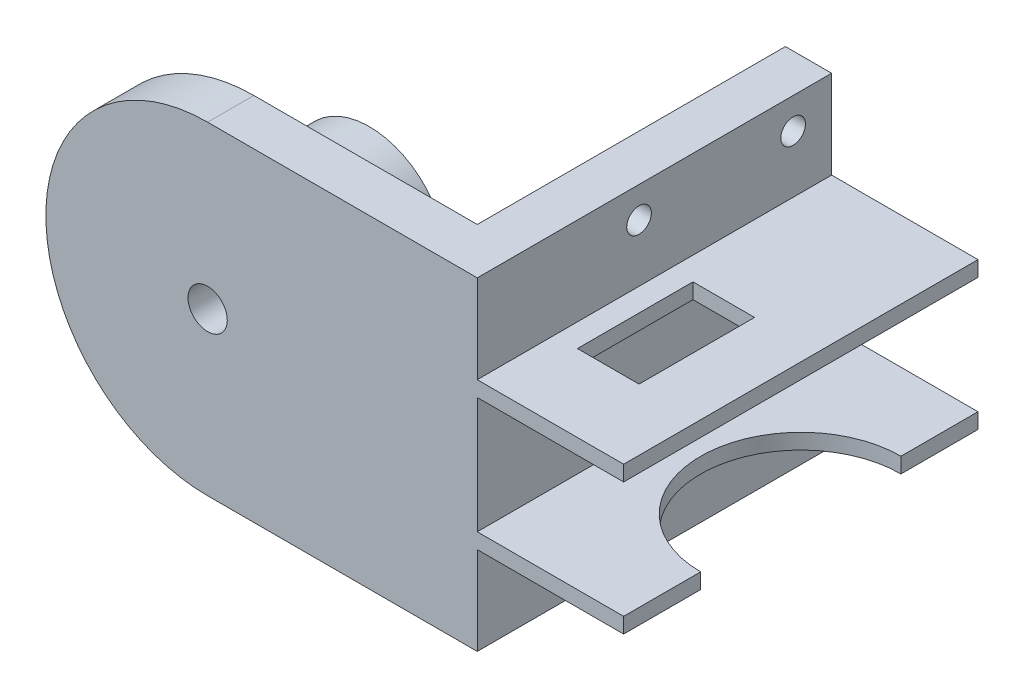
from build123d import *

# Parameters (mm, degrees)
SKETCH_1_R          = 10
SKETCH_1_R_2        = 2.55
EXTRUDE_1_DEPTH     = 15
SKETCH_3_R          = 1.6
CUT_EXTRUDE_1_DEPTH = 21
EXTRUDE_2_DEPTH     = 6
SKETCH_6_R          = 2.55
CUT_EXTRUDE_2_DEPTH = 10
SKETCH_7_W          = 40
SKETCH_7_H          = 42
EXTRUDE_3_DEPTH     = 6
SKETCH_8_R          = 1.6
CUT_EXTRUDE_3_DEPTH = 6
SKETCH_9_W          = 46
SKETCH_9_H          = 2
EXTRUDE_4_DEPTH     = 19
SKETCH_10_R         = 13
CUT_EXTRUDE_4_DEPTH = 8
SKETCH_11_W         = 8
SKETCH_11_H         = 15
CUT_EXTRUDE_5_DEPTH = 8


with BuildPart() as part:
    # 草图1 → 凸台-拉伸1 (new body)
    with BuildSketch(Plane.XY):
        with Locations((-2.14168272, 2.06384273)):
            Circle(SKETCH_1_R)
        with Locations((-2.14168272, 2.06384273)):
            Circle(SKETCH_1_R_2, mode=Mode.SUBTRACT)
    extrude(amount=EXTRUDE_1_DEPTH)

    # 草图3 → 切除-拉伸1 (cut, through all)
    with BuildSketch(Plane(origin=(7.85831728, 0, 0), x_dir=(0, 0, -1), z_dir=(1, 0, 0))):
        with Locations((-7.5, 2.06384273)):
            Circle(SKETCH_3_R)
    extrude(amount=-CUT_EXTRUDE_1_DEPTH, mode=Mode.SUBTRACT)

    # 草图5 → 凸台-拉伸2 (add)
    with BuildSketch(Plane.XY.offset(15)):
        with BuildLine():
            Line((-2.14168272, 23.06384273), (32.85831728, 23.06384273))
            Line((32.85831728, 23.06384273), (32.85831728, -18.93615727))
            Line((32.85831728, -18.93615727), (-2.14168272, -18.93615727))
            ThreePointArc((-2.14168272, -18.93615727), (-23.14168272, 2.06384273), (-2.14168272, 23.06384273))
        make_face()
    extrude(amount=EXTRUDE_2_DEPTH)

    # 草图6 → 切除-拉伸2 (cut)
    with BuildSketch(Plane(origin=(0, 0, 15), x_dir=(-1, 0, 0), z_dir=(0, 0, -1))):
        with Locations((2.14168272, 2.06384273)):
            Circle(SKETCH_6_R)
    extrude(amount=-CUT_EXTRUDE_2_DEPTH, mode=Mode.SUBTRACT)

    # 草图7 → 凸台-拉伸3 (add)
    with BuildSketch(Plane(origin=(32.85831728, 0, 0), x_dir=(0, 0, -1), z_dir=(1, 0, 0))):
        with Locations((5, 2.06384273)):
            Rectangle(SKETCH_7_W, SKETCH_7_H)
    extrude(amount=-EXTRUDE_3_DEPTH)

    # 草图8 → 切除-拉伸3 (cut)
    with BuildSketch(Plane(origin=(32.85831728, 0, 0), x_dir=(0, 0, -1), z_dir=(1, 0, 0))):
        with Locations((0, 19.06384273)):
            Circle(SKETCH_8_R)
        with Locations((0, -14.93615727)):
            Circle(SKETCH_8_R)
        with Locations((20, -14.93615727)):
            Circle(SKETCH_8_R)
        with Locations((20, 19.06384273)):
            Circle(SKETCH_8_R)
    extrude(amount=-CUT_EXTRUDE_3_DEPTH, mode=Mode.SUBTRACT)

    # 草图9 → 凸台-拉伸4 (add)
    with BuildSketch(Plane(origin=(32.85831728, 0, 0), x_dir=(0, 0, -1), z_dir=(1, 0, 0))):
        with Locations((2, 10.61384273)):
            Rectangle(SKETCH_9_W, SKETCH_9_H)
        with Locations((2, -6.48615727)):
            Rectangle(SKETCH_9_W, SKETCH_9_H)
    extrude(amount=EXTRUDE_4_DEPTH)

    # 草图10 → 切除-拉伸4 (cut)
    with BuildSketch(Plane.XZ.offset(7.48615727)):
        with Locations((51.85831728, -2)):
            Circle(SKETCH_10_R)
    extrude(amount=-CUT_EXTRUDE_4_DEPTH, mode=Mode.SUBTRACT)

    # 草图11 → 切除-拉伸5 (cut)
    with BuildSketch(Plane(origin=(0, 11.61384273, 0), x_dir=(1, 0, 0), z_dir=(0, 1, 0))):
        with Locations((39.85831728, -3.5)):
            Rectangle(SKETCH_11_W, SKETCH_11_H)
    extrude(amount=-CUT_EXTRUDE_5_DEPTH, mode=Mode.SUBTRACT)


solid = part.part
